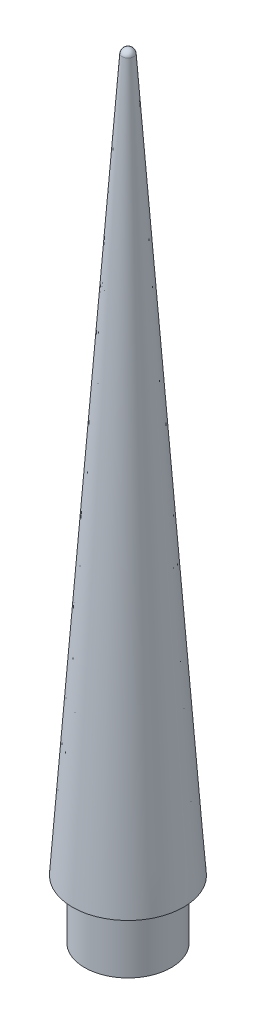
from build123d import *

# Parameters (mm, degrees)
SKETCH1_R                     = 9.398
BOSS_EXTRUDE1_DEPTH           = 12.7
TAP_DRILL_FOR_8_32_TAP1_D     = 3.4544
TAP_DRILL_FOR_8_32_TAP1_DEPTH = 10.16
TAP_DRILL_FOR_8_32_TAP1_TIP   = 1.037806461


with BuildPart() as part:
    # Sketch1 → Boss-Extrude1 (new body)
    with BuildSketch(Plane(origin=(0, 0, 0), x_dir=(1, 0, 0), z_dir=(0, 1, 0))):
        Circle(SKETCH1_R)
    extrude(amount=BOSS_EXTRUDE1_DEPTH)

    # Sketch3 → Revolve1 (revolve)
    with BuildSketch(Plane(origin=(0, 0, 0), x_dir=(0, 0, -1), z_dir=(1, 0, 0))):
        with BuildLine():
            Line((0, 12.7), (12.065, 12.7))
            Line((12.065, 12.7), (1.27, 167.075692241))
            Line((1.27, 167.075692241), (1.257640447, 167.252442079))
            ThreePointArc((1.257640447, 167.252442079), (0.833194967, 168.034173408), (0, 168.345692241))
            Line((0, 168.345692241), (0, 12.7))
        make_face()
    revolve(axis=Axis((0, 185.237538387, 0), (0, -1, 0)))

    # Tap Drill for #8-32 Tap1
    with Locations(Plane(origin=(0, 0, 0), x_dir=(-1, 0, 0), z_dir=(0, -1, 0))):
        with Locations((0, 0)):
            Hole(TAP_DRILL_FOR_8_32_TAP1_D / 2, depth=TAP_DRILL_FOR_8_32_TAP1_DEPTH)
            with Locations((0, 0, -(TAP_DRILL_FOR_8_32_TAP1_DEPTH + TAP_DRILL_FOR_8_32_TAP1_TIP / 2))):  # 118° drill point
                Cone(0, TAP_DRILL_FOR_8_32_TAP1_D / 2, TAP_DRILL_FOR_8_32_TAP1_TIP, mode=Mode.SUBTRACT)


solid = part.part
